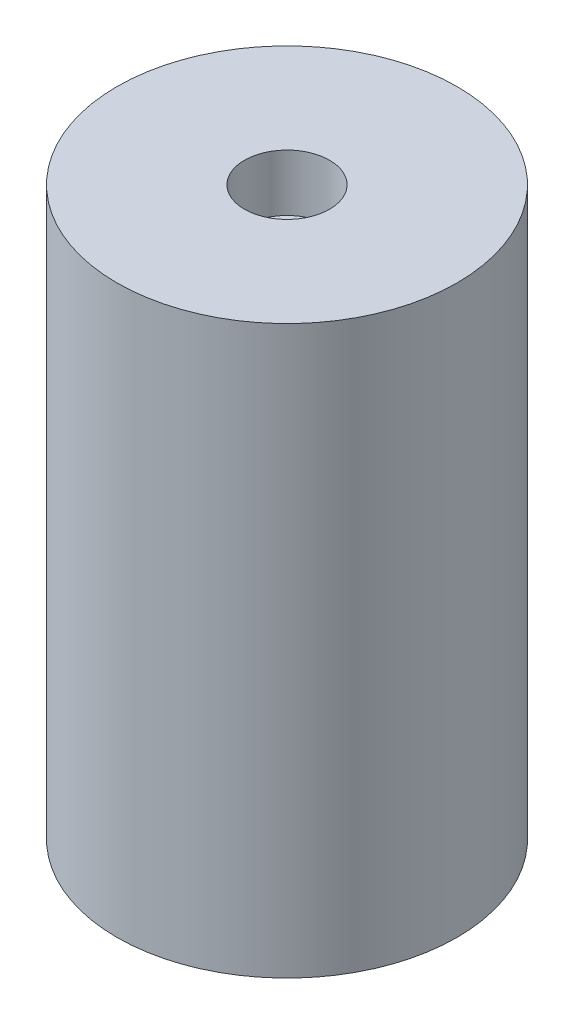
from build123d import *

# Parameters (mm, degrees)
SKETCH1_R           = 6
BOSS_EXTRUDE1_DEPTH = 20
SKETCH2_R           = 1.5
CUT_EXTRUDE1_DEPTH  = 2


with BuildPart() as part:
    # Sketch1 → Boss-Extrude1 (new body)
    with BuildSketch(Plane(origin=(0, 0, 0), x_dir=(1, 0, 0), z_dir=(0, 1, 0))):
        Circle(SKETCH1_R)
    extrude(amount=BOSS_EXTRUDE1_DEPTH)

    # Sketch2 → Cut-Extrude1 (cut)
    with BuildSketch(Plane(origin=(0, 20, 0), x_dir=(1, 0, 0), z_dir=(0, 1, 0))):
        Circle(SKETCH2_R)
    extrude(amount=-CUT_EXTRUDE1_DEPTH, mode=Mode.SUBTRACT)


solid = part.part
